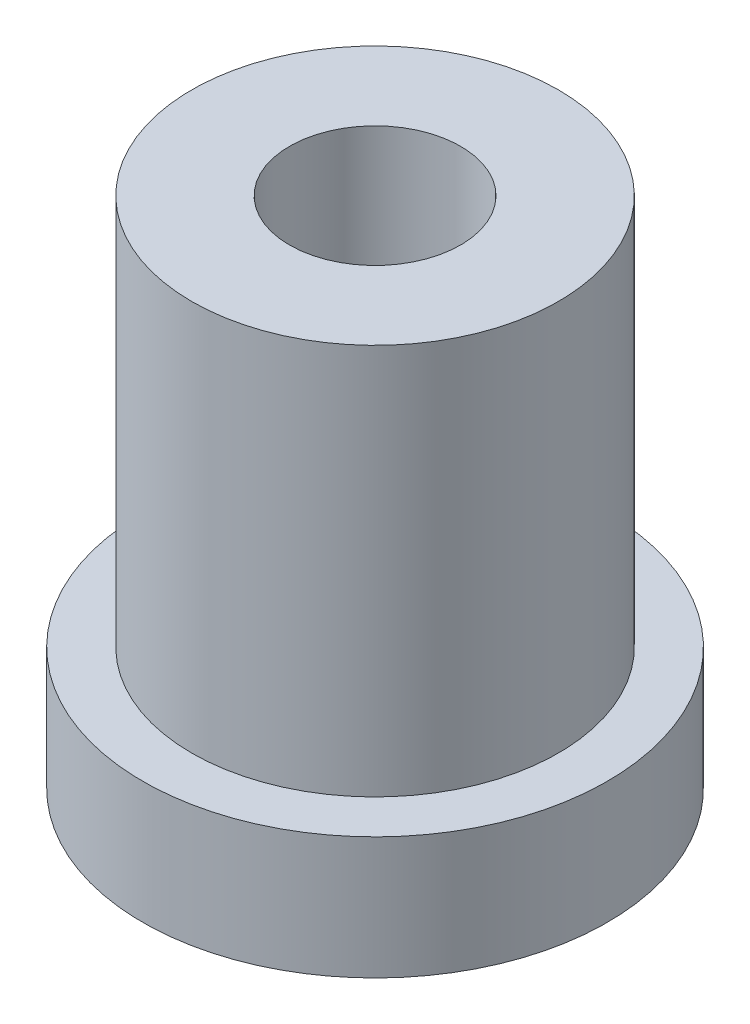
from build123d import *

# Parameters (mm, degrees)
SKETCH1_R                  = 3.75
BOSS_EXTRUDE1_DEPTH        = 10.5
F_3_5_3_5_DIAMETER_HOLE1_D = 3.5
SKETCH5_R                  = 4.75
SKETCH5_R_2                = 3.75
BOSS_EXTRUDE2_DEPTH        = 2.5


with BuildPart() as part:
    # Sketch1 → Boss-Extrude1 (new body)
    with BuildSketch(Plane(origin=(0, 0, 0), x_dir=(1, 0, 0), z_dir=(0, 1, 0))):
        Circle(SKETCH1_R)
    extrude(amount=BOSS_EXTRUDE1_DEPTH)

    # Ø3.5 (3.5) Diameter Hole1 (through all)
    with Locations(Plane(origin=(0, 10.5, 0), x_dir=(1, 0, 0), z_dir=(0, 1, 0))):
        with Locations((0, 0)):
            Hole(F_3_5_3_5_DIAMETER_HOLE1_D / 2)

    # Sketch5 → Boss-Extrude2 (add)
    with BuildSketch(Plane.XZ):
        Circle(SKETCH5_R)
        Circle(SKETCH5_R_2, mode=Mode.SUBTRACT)
    extrude(amount=-BOSS_EXTRUDE2_DEPTH)


solid = part.part
